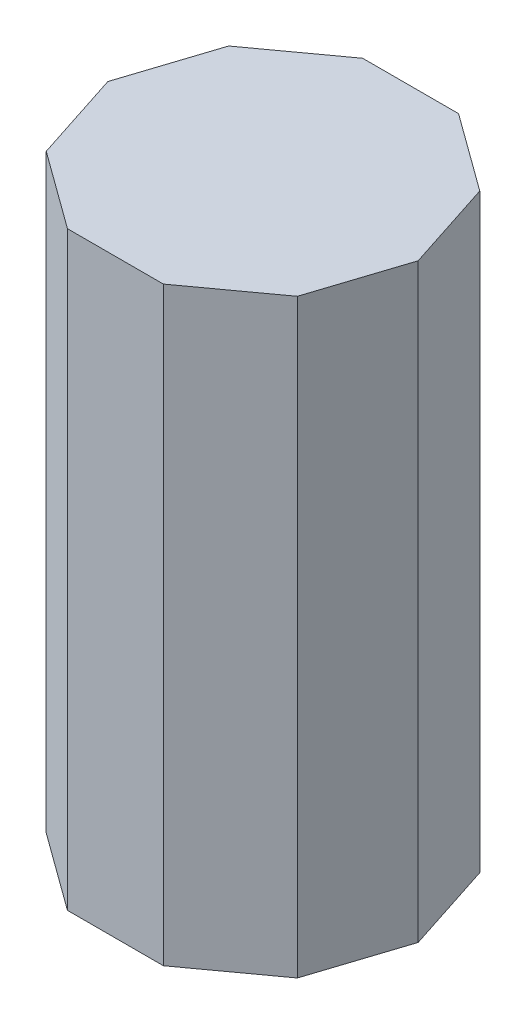
from build123d import *

# Parameters (mm, degrees)
EXTRUDE1_DEPTH = 20


with BuildPart() as part:
    # Sketch1 → Extrude1 (new body)
    with BuildSketch(Plane(origin=(0, 0, 0), x_dir=(1, 0, 0), z_dir=(0, 1, 0))):
        Polygon((4.253254042, -3.090169944), (5.257311121, 0), (4.253254042, 3.090169944), (1.624598481, 5), (-1.624598481, 5), (-4.253254042, 3.090169944), (-5.257311121, 0), (-4.253254042, -3.090169944), (-1.624598481, -5), (1.624598481, -5), align=None)
    extrude(amount=EXTRUDE1_DEPTH)


solid = part.part
